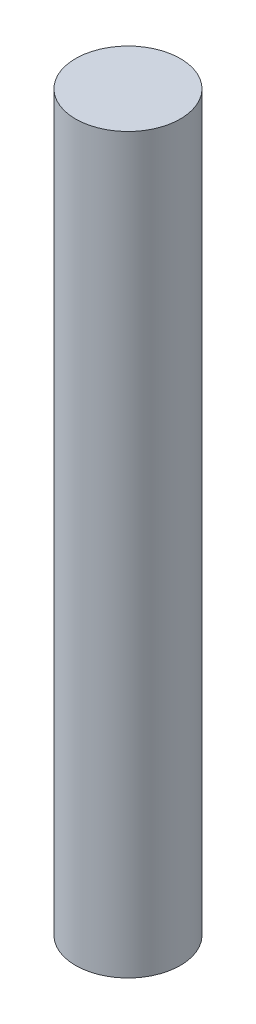
from build123d import *

# Parameters (mm, degrees)
SKETCH1_R           = 1
BOSS_EXTRUDE1_DEPTH = 14


with BuildPart() as part:
    # Sketch1 → Boss-Extrude1 (new body)
    with BuildSketch(Plane(origin=(0, 0, 0), x_dir=(1, 0, 0), z_dir=(0, 1, 0))):
        Circle(SKETCH1_R)
    extrude(amount=BOSS_EXTRUDE1_DEPTH)


solid = part.part
